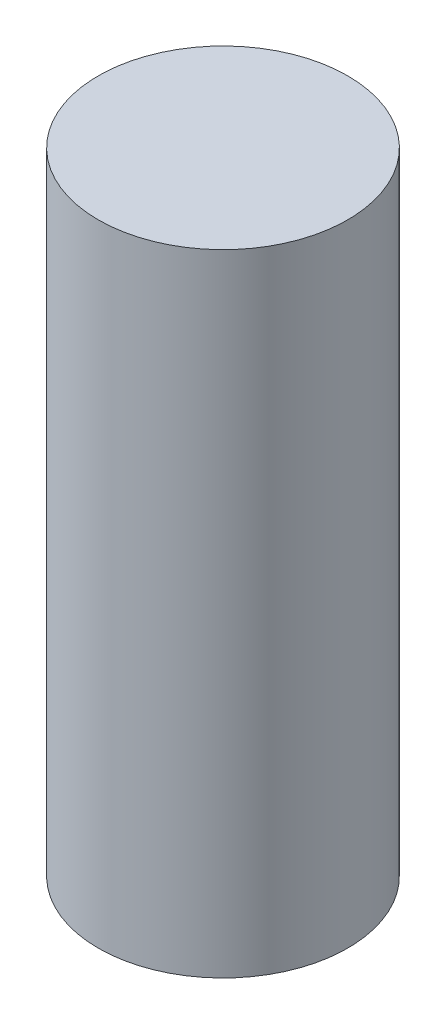
from build123d import *

# Parameters (mm, degrees)
SKETCH1_R           = 16.637
BOSS_EXTRUDE1_DEPTH = 84.1248


with BuildPart() as part:
    # Sketch1 → Boss-Extrude1 (new body)
    with BuildSketch(Plane(origin=(0, 0, 0), x_dir=(1, 0, 0), z_dir=(0, 1, 0))):
        Circle(SKETCH1_R)
    extrude(amount=BOSS_EXTRUDE1_DEPTH)


solid = part.part
